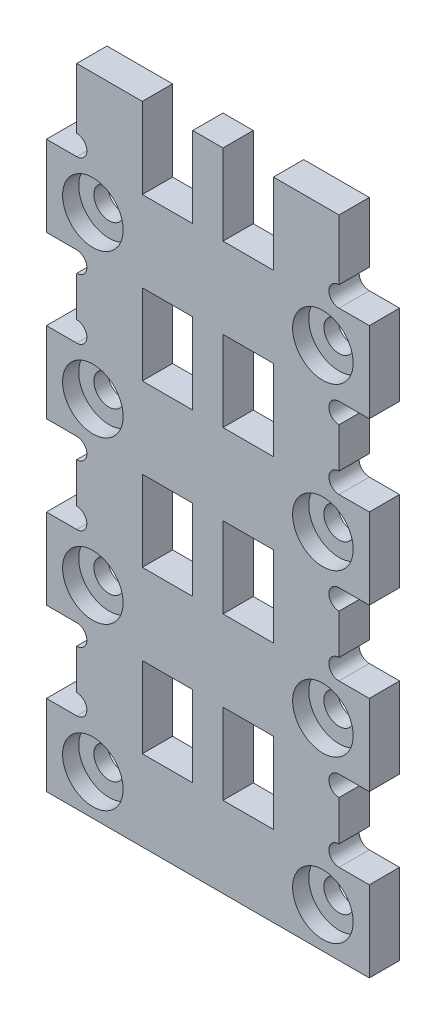
from build123d import *

# Parameters (mm, degrees)
EXTRUDE_1_DEPTH     = 3
SKETCH_2_W          = 5
SKETCH_2_H          = 8
CUT_EXTRUDE_1_DEPTH = 3
SKETCH_3_R          = 1.5
CUT_EXTRUDE_2_DEPTH = 3
SKETCH_4_R          = 3
CUT_EXTRUDE_3_DEPTH = 1.6
CUT_EXTRUDE_4_REACH = 5
SKETCH_5_R          = 1.005


with BuildPart() as part:
    # 草图1 → 凸台-拉伸1 (new body)
    with BuildSketch(Plane.XY):
        Polygon((16, 0), (-16, 0), (-16, 8), (-13, 8), (-13, 16), (-16, 16), (-16, 24), (-13, 24), (-13, 32), (-16, 32), (-16, 40), (-13, 40), (-13, 48), (-16, 48), (-16, 56), (-13, 56), (-13, 64), (13, 64), (13, 56), (16, 56), (16, 48), (13, 48), (13, 40), (16, 40), (16, 32), (13, 32), (13, 24), (16, 24), (16, 16), (13, 16), (13, 8), (16, 8), align=None)
    extrude(amount=EXTRUDE_1_DEPTH)

    # 草图2 → 切除-拉伸1 (cut)
    with BuildSketch(Plane.XY.offset(3)):
        with Locations((-4, 28)):
            Rectangle(SKETCH_2_W, SKETCH_2_H)
        with Locations((-4, 12)):
            Rectangle(SKETCH_2_W, SKETCH_2_H)
        with Locations((4, 28)):
            Rectangle(SKETCH_2_W, SKETCH_2_H)
        with Locations((-4, 44)):
            Rectangle(SKETCH_2_W, SKETCH_2_H)
        with Locations((4, 44)):
            Rectangle(SKETCH_2_W, SKETCH_2_H)
        with Locations((4, 12)):
            Rectangle(SKETCH_2_W, SKETCH_2_H)
        with Locations((4, 60)):
            Rectangle(SKETCH_2_W, SKETCH_2_H)
        with Locations((-4, 60)):
            Rectangle(SKETCH_2_W, SKETCH_2_H)
    extrude(amount=-CUT_EXTRUDE_1_DEPTH, mode=Mode.SUBTRACT)

    # 草图3 → 切除-拉伸2 (cut)
    with BuildSketch(Plane.XY.offset(3)):
        with Locations((-11.4, 4)):
            Circle(SKETCH_3_R)
        with Locations((11.4, 4)):
            Circle(SKETCH_3_R)
        with Locations((-11.4, 20)):
            Circle(SKETCH_3_R)
        with Locations((11.4, 20)):
            Circle(SKETCH_3_R)
        with Locations((-11.4, 36)):
            Circle(SKETCH_3_R)
        with Locations((11.4, 36)):
            Circle(SKETCH_3_R)
        with Locations((-11.4, 52)):
            Circle(SKETCH_3_R)
        with Locations((11.4, 52)):
            Circle(SKETCH_3_R)
    extrude(amount=-CUT_EXTRUDE_2_DEPTH, mode=Mode.SUBTRACT)

    # 草图4 → 切除-拉伸3 (cut)
    with BuildSketch(Plane.XY.offset(3)):
        with Locations((-11.4, 4)):
            Circle(SKETCH_4_R)
        with Locations((11.4, 4)):
            Circle(SKETCH_4_R)
        with Locations((-11.4, 20)):
            Circle(SKETCH_4_R)
        with Locations((11.4, 20)):
            Circle(SKETCH_4_R)
        with Locations((-11.4, 36)):
            Circle(SKETCH_4_R)
        with Locations((11.4, 36)):
            Circle(SKETCH_4_R)
        with Locations((-11.4, 52)):
            Circle(SKETCH_4_R)
        with Locations((11.4, 52)):
            Circle(SKETCH_4_R)
    extrude(amount=-CUT_EXTRUDE_3_DEPTH, mode=Mode.SUBTRACT)

    # 草图5 → 切除-拉伸4 (cut, up to next)
    with BuildSketch(Plane.XY.offset(3), mode=Mode.PRIVATE) as cut_extrude_4_sk1:
        with Locations((-13, 57.005)):
            Circle(SKETCH_5_R)
    cut_extrude_4_tool1 = extrude(cut_extrude_4_sk1.sketch, amount=-CUT_EXTRUDE_4_REACH, mode=Mode.PRIVATE) & part.part
    add(cut_extrude_4_tool1.solids().sort_by_distance((-13, 57.005, 3))[0], mode=Mode.SUBTRACT)
    # 草图5 → 切除-拉伸4 (cut, up to next)
    with BuildSketch(Plane.XY.offset(3), mode=Mode.PRIVATE) as cut_extrude_4_sk2:
        with Locations((-13, 46.995)):
            Circle(SKETCH_5_R)
    cut_extrude_4_tool2 = extrude(cut_extrude_4_sk2.sketch, amount=-CUT_EXTRUDE_4_REACH, mode=Mode.PRIVATE) & part.part
    add(cut_extrude_4_tool2.solids().sort_by_distance((-13, 46.995, 3))[0], mode=Mode.SUBTRACT)
    # 草图5 → 切除-拉伸4 (cut, up to next)
    with BuildSketch(Plane.XY.offset(3), mode=Mode.PRIVATE) as cut_extrude_4_sk3:
        with Locations((-13, 41.005)):
            Circle(SKETCH_5_R)
    cut_extrude_4_tool3 = extrude(cut_extrude_4_sk3.sketch, amount=-CUT_EXTRUDE_4_REACH, mode=Mode.PRIVATE) & part.part
    add(cut_extrude_4_tool3.solids().sort_by_distance((-13, 41.005, 3))[0], mode=Mode.SUBTRACT)
    # 草图5 → 切除-拉伸4 (cut, up to next)
    with BuildSketch(Plane.XY.offset(3), mode=Mode.PRIVATE) as cut_extrude_4_sk4:
        with Locations((-13, 30.995)):
            Circle(SKETCH_5_R)
    cut_extrude_4_tool4 = extrude(cut_extrude_4_sk4.sketch, amount=-CUT_EXTRUDE_4_REACH, mode=Mode.PRIVATE) & part.part
    add(cut_extrude_4_tool4.solids().sort_by_distance((-13, 30.995, 3))[0], mode=Mode.SUBTRACT)
    # 草图5 → 切除-拉伸4 (cut, up to next)
    with BuildSketch(Plane.XY.offset(3), mode=Mode.PRIVATE) as cut_extrude_4_sk5:
        with Locations((-13, 25.005)):
            Circle(SKETCH_5_R)
    cut_extrude_4_tool5 = extrude(cut_extrude_4_sk5.sketch, amount=-CUT_EXTRUDE_4_REACH, mode=Mode.PRIVATE) & part.part
    add(cut_extrude_4_tool5.solids().sort_by_distance((-13, 25.005, 3))[0], mode=Mode.SUBTRACT)
    # 草图5 → 切除-拉伸4 (cut, up to next)
    with BuildSketch(Plane.XY.offset(3), mode=Mode.PRIVATE) as cut_extrude_4_sk6:
        with Locations((-13, 14.995)):
            Circle(SKETCH_5_R)
    cut_extrude_4_tool6 = extrude(cut_extrude_4_sk6.sketch, amount=-CUT_EXTRUDE_4_REACH, mode=Mode.PRIVATE) & part.part
    add(cut_extrude_4_tool6.solids().sort_by_distance((-13, 14.995, 3))[0], mode=Mode.SUBTRACT)
    # 草图5 → 切除-拉伸4 (cut, up to next)
    with BuildSketch(Plane.XY.offset(3), mode=Mode.PRIVATE) as cut_extrude_4_sk7:
        with Locations((-13, 9.005)):
            Circle(SKETCH_5_R)
    cut_extrude_4_tool7 = extrude(cut_extrude_4_sk7.sketch, amount=-CUT_EXTRUDE_4_REACH, mode=Mode.PRIVATE) & part.part
    add(cut_extrude_4_tool7.solids().sort_by_distance((-13, 9.005, 3))[0], mode=Mode.SUBTRACT)
    # 草图5 → 切除-拉伸4 (cut, up to next)
    with BuildSketch(Plane.XY.offset(3), mode=Mode.PRIVATE) as cut_extrude_4_sk8:
        with Locations((13, 9.005)):
            Circle(SKETCH_5_R)
    cut_extrude_4_tool8 = extrude(cut_extrude_4_sk8.sketch, amount=-CUT_EXTRUDE_4_REACH, mode=Mode.PRIVATE) & part.part
    add(cut_extrude_4_tool8.solids().sort_by_distance((13, 9.005, 3))[0], mode=Mode.SUBTRACT)
    # 草图5 → 切除-拉伸4 (cut, up to next)
    with BuildSketch(Plane.XY.offset(3), mode=Mode.PRIVATE) as cut_extrude_4_sk9:
        with Locations((13, 14.995)):
            Circle(SKETCH_5_R)
    cut_extrude_4_tool9 = extrude(cut_extrude_4_sk9.sketch, amount=-CUT_EXTRUDE_4_REACH, mode=Mode.PRIVATE) & part.part
    add(cut_extrude_4_tool9.solids().sort_by_distance((13, 14.995, 3))[0], mode=Mode.SUBTRACT)
    # 草图5 → 切除-拉伸4 (cut, up to next)
    with BuildSketch(Plane.XY.offset(3), mode=Mode.PRIVATE) as cut_extrude_4_sk10:
        with Locations((13, 25.005)):
            Circle(SKETCH_5_R)
    cut_extrude_4_tool10 = extrude(cut_extrude_4_sk10.sketch, amount=-CUT_EXTRUDE_4_REACH, mode=Mode.PRIVATE) & part.part
    add(cut_extrude_4_tool10.solids().sort_by_distance((13, 25.005, 3))[0], mode=Mode.SUBTRACT)
    # 草图5 → 切除-拉伸4 (cut, up to next)
    with BuildSketch(Plane.XY.offset(3), mode=Mode.PRIVATE) as cut_extrude_4_sk11:
        with Locations((13, 30.995)):
            Circle(SKETCH_5_R)
    cut_extrude_4_tool11 = extrude(cut_extrude_4_sk11.sketch, amount=-CUT_EXTRUDE_4_REACH, mode=Mode.PRIVATE) & part.part
    add(cut_extrude_4_tool11.solids().sort_by_distance((13, 30.995, 3))[0], mode=Mode.SUBTRACT)
    # 草图5 → 切除-拉伸4 (cut, up to next)
    with BuildSketch(Plane.XY.offset(3), mode=Mode.PRIVATE) as cut_extrude_4_sk12:
        with Locations((13, 41.005)):
            Circle(SKETCH_5_R)
    cut_extrude_4_tool12 = extrude(cut_extrude_4_sk12.sketch, amount=-CUT_EXTRUDE_4_REACH, mode=Mode.PRIVATE) & part.part
    add(cut_extrude_4_tool12.solids().sort_by_distance((13, 41.005, 3))[0], mode=Mode.SUBTRACT)
    # 草图5 → 切除-拉伸4 (cut, up to next)
    with BuildSketch(Plane.XY.offset(3), mode=Mode.PRIVATE) as cut_extrude_4_sk13:
        with Locations((13, 46.995)):
            Circle(SKETCH_5_R)
    cut_extrude_4_tool13 = extrude(cut_extrude_4_sk13.sketch, amount=-CUT_EXTRUDE_4_REACH, mode=Mode.PRIVATE) & part.part
    add(cut_extrude_4_tool13.solids().sort_by_distance((13, 46.995, 3))[0], mode=Mode.SUBTRACT)
    # 草图5 → 切除-拉伸4 (cut, up to next)
    with BuildSketch(Plane.XY.offset(3), mode=Mode.PRIVATE) as cut_extrude_4_sk14:
        with Locations((13, 57.005)):
            Circle(SKETCH_5_R)
    cut_extrude_4_tool14 = extrude(cut_extrude_4_sk14.sketch, amount=-CUT_EXTRUDE_4_REACH, mode=Mode.PRIVATE) & part.part
    add(cut_extrude_4_tool14.solids().sort_by_distance((13, 57.005, 3))[0], mode=Mode.SUBTRACT)


solid = part.part
